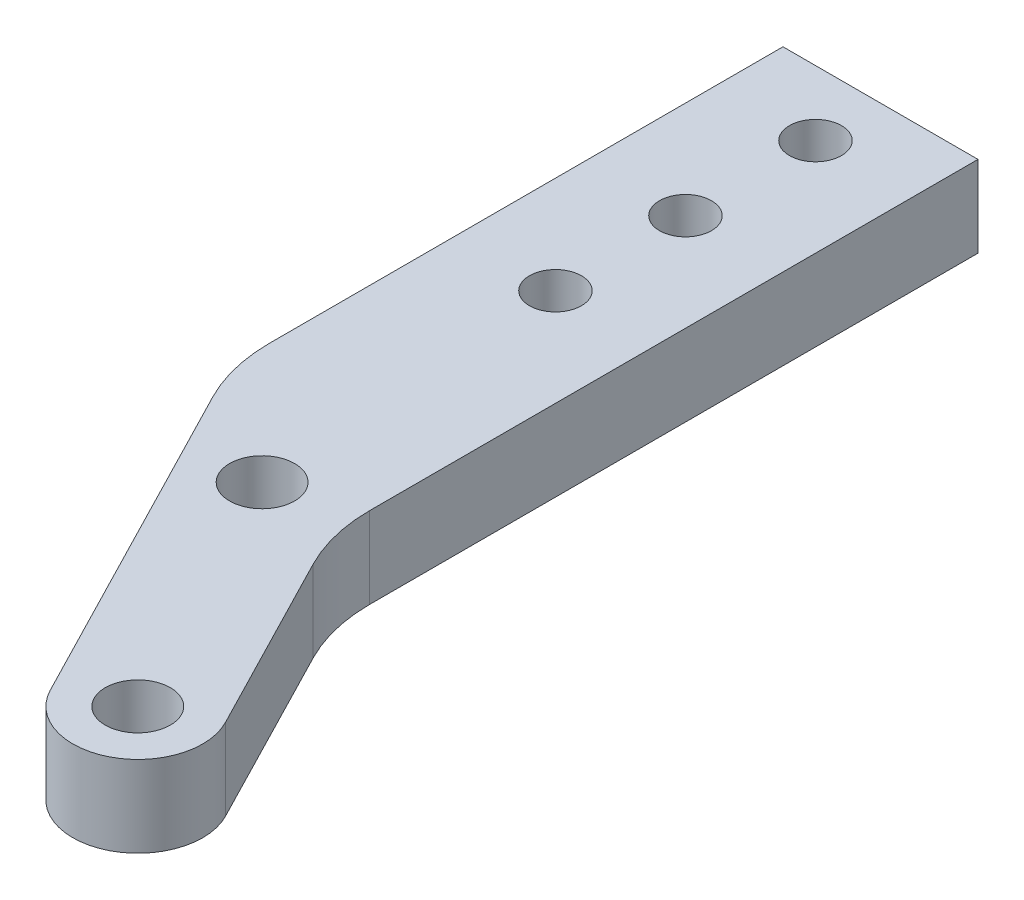
from build123d import *

# Parameters (mm, degrees)
EXTRUDE_1_DEPTH         = 5
HOLE_WIZARD_A_0_234_3_D = 3.1999936
PATTERN_LINEAR_1_COUNT  = 3
PATTERN_LINEAR_1_PITCH  = 8
HOLE_WIZARD_A_0_234_4_D = 4


with BuildPart() as part:
    # Эскиз1 → Бобышка-Вытянуть1 (new body)
    with BuildSketch(Plane.XZ):
        with BuildLine():
            Line((-6, 31.613261479), (-6, 0))
            Line((-6, 0), (6, 0))
            Line((6, 0), (6, 37.436574312))
            ThreePointArc((6, 37.436574312), (6.281622528, 39.793084297), (7.110627862, 42.016865021))
            Line((7.110627862, 42.016865021), (12.856242572, 53.167883716))
            ThreePointArc((12.856242572, 53.167883716), (11.13261, 58.555748855), (5.744744861, 56.832116284))
            Line((5.744744861, 56.832116284), (-4.889372139, 36.193552189))
            ThreePointArc((-4.889372139, 36.193552189), (-5.718377472, 33.969771464), (-6, 31.613261479))
        make_face()
    extrude(amount=-EXTRUDE_1_DEPTH)

    # Диаметр отверстия A (0.234)3 (through all)
    with Locations(Plane(origin=(0, 0, 4), x_dir=(0, 0, -1), z_dir=(0, -1, 0))):
        with Locations((0, 0)):
            hole_wizard_a_0_234_3 = Hole(HOLE_WIZARD_A_0_234_3_D / 2)

    # Линейный массив1: Диаметр отверстия A (0.234)3 ×3
    with Locations(*[(0, 0, i * PATTERN_LINEAR_1_PITCH) for i in range(1, PATTERN_LINEAR_1_COUNT)]):
        add(hole_wizard_a_0_234_3, mode=Mode.SUBTRACT)

    # Диаметр отверстия A (0.234)4 (through all)
    with Locations(Plane(origin=(9.3, 0, 55), x_dir=(0, 0, -1), z_dir=(0, -1, 0))):
        with Locations((0, 0), (15.76854256, -8.11912081)):
            Hole(HOLE_WIZARD_A_0_234_4_D / 2)


solid = part.part
